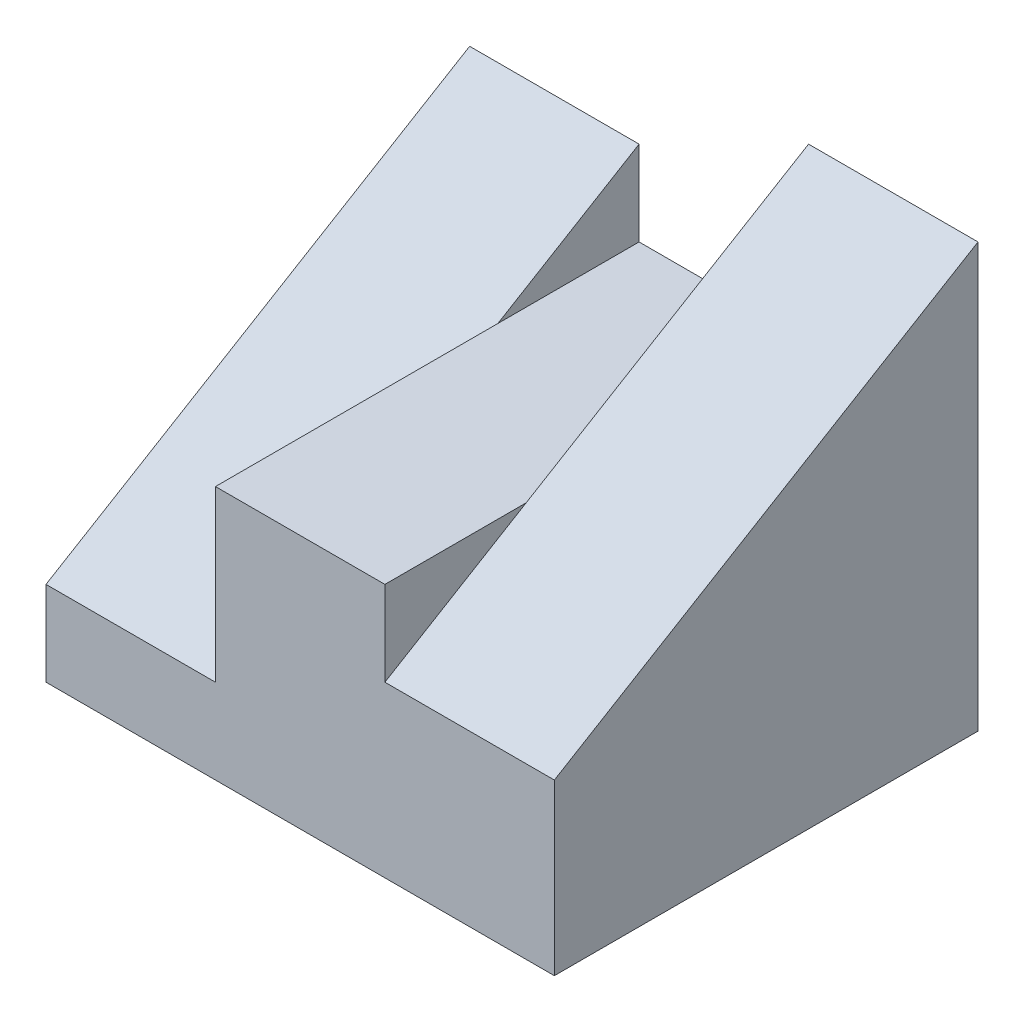
from build123d import *

# Parameters (mm, degrees)
BOSS_EXTRUDE1_DEPTH = 25
BOSS_EXTRUDE2_DEPTH = 10
BOSS_EXTRUDE3_DEPTH = 10


with BuildPart() as part:
    # Sketch1 → Boss-Extrude1 (new body)
    with BuildSketch(Plane.XY):
        Polygon((-30, 5), (-20, 5), (-20, 15), (-10, 15), (-10, 10), (0, 10), (0, 0), (-30, 0), align=None)
    extrude(amount=BOSS_EXTRUDE1_DEPTH)

    # Sketch2 → Boss-Extrude2 (add)
    with BuildSketch(Plane(origin=(-10, 0, 0), x_dir=(0, 0, -1), z_dir=(1, 0, 0))):
        Polygon((-25, 10), (0, 10), (0, 25), align=None)
    extrude(amount=BOSS_EXTRUDE2_DEPTH)

    # Sketch3 → Boss-Extrude3 (add)
    with BuildSketch(Plane.ZY.offset(20)):
        Polygon((0, 5), (0, 20), (25, 5), align=None)
    extrude(amount=BOSS_EXTRUDE3_DEPTH)


solid = part.part
